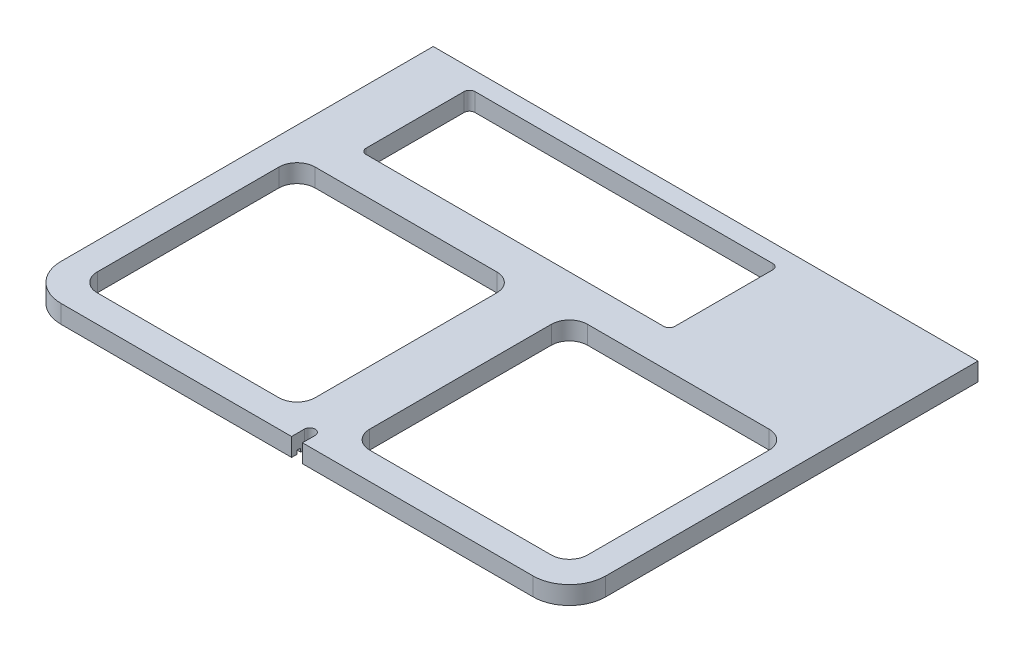
from build123d import *

# Parameters (mm, degrees)
SKIZZE1_W                       = 120
SKIZZE1_H                       = 120
LINEAR_AUSTRAGEN1_DEPTH         = 10
VERRUNDUNG2_R                   = 10
VERRUNDUNG2_OF_SPIEGELN1_R      = 10
SKIZZE3_W                       = 170
SKIZZE3_H                       = 60
SCHNITT_LINEAR_AUSTRAGEN1_DEPTH = 10
VERRUNDUNG3_R                   = 3
SCHNITT_LINEAR_AUSTRAGEN2_DEPTH = 10
SKIZZE5_W                       = 14
SKIZZE5_H                       = 2
SCHNITT_LINEAR_AUSTRAGEN3_DEPTH = 2


with BuildPart() as part:
    # Skizze1 → Linear austragen1 (new body)
    with BuildSketch(Plane(origin=(0, 10, 0), x_dir=(1, 0, 0), z_dir=(0, 1, 0))):
        with BuildLine():
            Line((0, -75), (130, -75))
            ThreePointArc((130, -75), (144.142135624, -69.142135624), (150, -55))
            Line((150, -55), (150, 75))
            Line((150, 75), (150, 150))
            Line((150, 150), (0, 150))
            Line((0, 150), (0, 75))
            Line((0, 75), (0, -75))
        make_face()
        with Locations((75, 0)):
            Rectangle(SKIZZE1_W, SKIZZE1_H, mode=Mode.SUBTRACT)
    linear_austragen1 = extrude(amount=LINEAR_AUSTRAGEN1_DEPTH)

    # Verrundung2
    verrundung2_edges = [part.edges().sort_by_distance(p)[0] for p in [
        (15, 15, -60),
        (15, 15, 60),
        (135, 15, 60),
        (135, 15, -60),
    ]]
    fillet(verrundung2_edges, radius=VERRUNDUNG2_R)

    # Spiegeln1: Linear austragen1 across plane
    add(linear_austragen1.mirror(Plane(origin=(0, 20, -150), x_dir=(0, 0, 1), z_dir=(1, 0, 0))))

    # Verrundung2 of Spiegeln1
    verrundung2_of_spiegeln1_edges = [part.edges().sort_by_distance(p)[0] for p in [
        (-15, 15, -60),
        (-15, 15, 60),
        (-135, 15, 60),
        (-135, 15, -60),
    ]]
    fillet(verrundung2_of_spiegeln1_edges, radius=VERRUNDUNG2_OF_SPIEGELN1_R)

    # Skizze3 → Schnitt-Linear austragen1 (cut)
    with BuildSketch(Plane.XZ.offset(-10)):
        with Locations((-35, -110)):
            Rectangle(SKIZZE3_W, SKIZZE3_H)
    extrude(amount=-SCHNITT_LINEAR_AUSTRAGEN1_DEPTH, mode=Mode.SUBTRACT)

    # Verrundung3
    verrundung3_edges = [part.edges().sort_by_distance(p)[0] for p in [
        (-120, 15, -140),
        (-120, 15, -80),
        (50, 15, -80),
        (50, 15, -140),
    ]]
    fillet(verrundung3_edges, radius=VERRUNDUNG3_R)

    # Skizze4 → Schnitt-Linear austragen2 (cut)
    with BuildSketch(Plane.XZ.offset(-10)):
        with BuildLine():
            Line((-3.000050853, 75), (-3.000050853, 68))
            ThreePointArc((-3.000050853, 68), (0.008683003, 65.000012713), (2.999898294, 68.017467638))
            Line((2.999898294, 68.017467638), (2.959241489, 75))
            Line((2.959241489, 75), (-3.000050853, 75))
        make_face()
    extrude(amount=-SCHNITT_LINEAR_AUSTRAGEN2_DEPTH, mode=Mode.SUBTRACT)

    # Skizze5 → Schnitt-Linear austragen3 (cut)
    with BuildSketch(Plane.XZ.offset(-10)):
        with Locations((-0.020404682, 71)):
            Rectangle(SKIZZE5_W, SKIZZE5_H)
    extrude(amount=-SCHNITT_LINEAR_AUSTRAGEN3_DEPTH, mode=Mode.SUBTRACT)


solid = part.part
